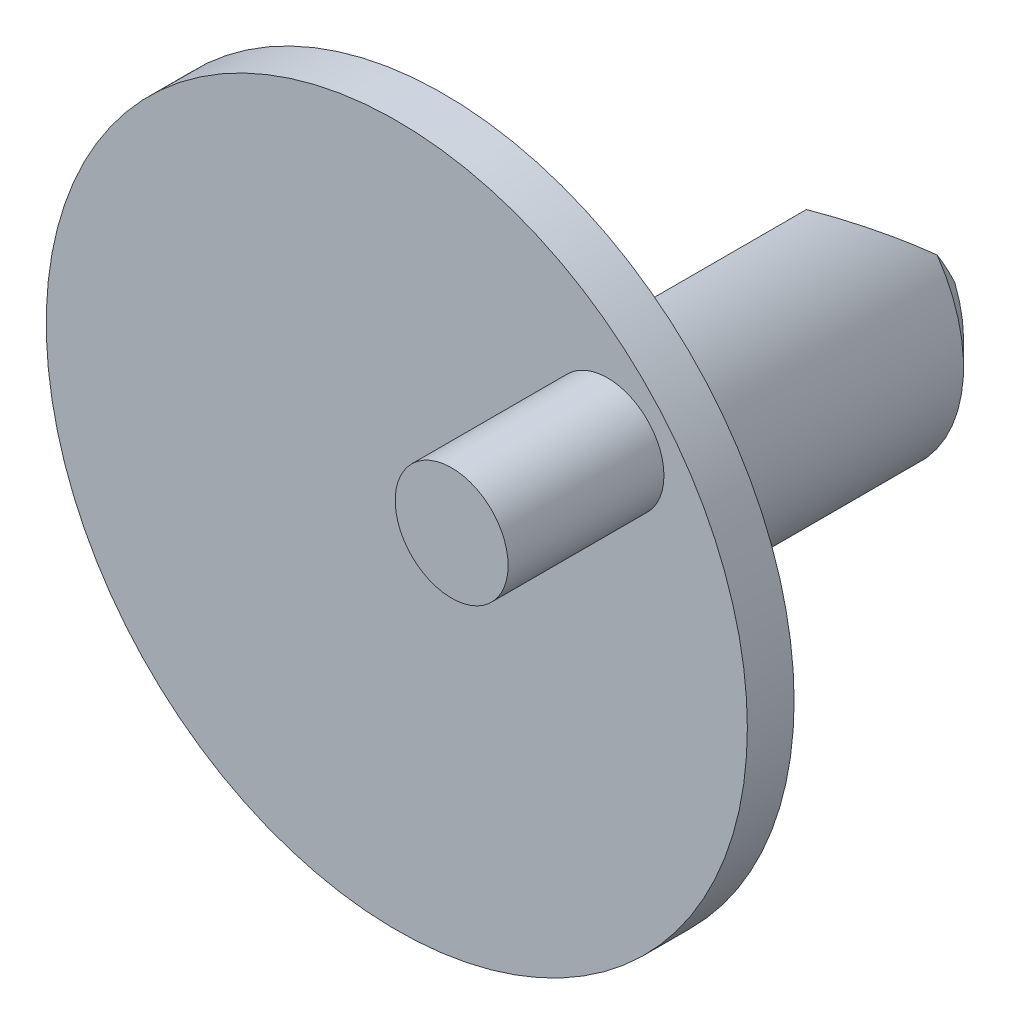
from build123d import *

# Parameters (mm, degrees)
SKETCH1_R           = 11.43
BOSS_EXTRUDE1_DEPTH = 1.524
BOSS_EXTRUDE2_DEPTH = 12.954
CHAMFER1_SIZE       = 3.175
CHAMFER2_SIZE       = 0.762
SKETCH3_R           = 1.8415
BOSS_EXTRUDE3_DEPTH = 5.08


with BuildPart() as part:
    # Sketch1 → Boss-Extrude1 (new body)
    with BuildSketch(Plane.XY):
        Circle(SKETCH1_R)
    extrude(amount=-BOSS_EXTRUDE1_DEPTH)

    # Sketch2 → Boss-Extrude2 (add)
    with BuildSketch(Plane(origin=(0, 0, -1.524), x_dir=(-1, 0, 0), z_dir=(0, 0, -1))):
        with BuildLine():
            Line((-2.052467985, 4.297532015), (4.297532015, -2.052467985))
            ThreePointArc((4.297532015, -2.052467985), (-3.367596045, -3.367596045), (-2.052467985, 4.297532015))
        make_face()
    extrude(amount=BOSS_EXTRUDE2_DEPTH)

    # Chamfer1
    chamfer1_edges = [part.edges().sort_by_distance(p)[0] for p in [
        (-1.122532015, 1.122532015, -14.478),
    ]]
    chamfer(chamfer1_edges, length=CHAMFER1_SIZE)

    # Chamfer2
    chamfer2_edges = [part.edges().sort_by_distance(p)[0] for p in [
        (3.367596045, -3.367596045, -14.478),
    ]]
    chamfer(chamfer2_edges, length=CHAMFER2_SIZE)

    # Sketch3 → Boss-Extrude3 (add)
    with BuildSketch(Plane.XY):
        with Locations((6.868507686, 5.763362266)):
            Circle(SKETCH3_R)
    extrude(amount=BOSS_EXTRUDE3_DEPTH)


solid = part.part
